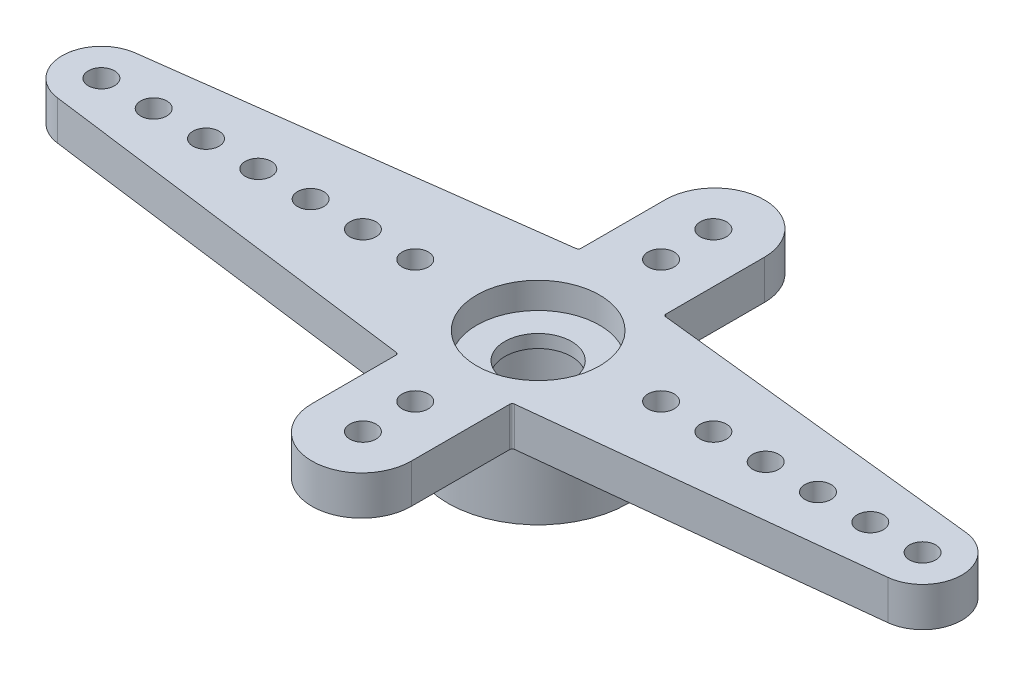
from build123d import *

# Parameters (mm, degrees)
IZIM1_R                     = 2.35
IZIM1_R_2                   = 0.5
Y_KSEKLIK_EKSTR_ZYON1_DEPTH = 1.5
IZIM1_3_R                   = 2.35
IZIM1_3_R_2                 = 1.275
Y_KSEKLIK_EKSTR_ZYON2_DEPTH = 0.5
IZIM2_R                     = 3.45
IZIM2_R_2                   = 2.3
Y_KSEKLIK_EKSTR_ZYON3_DEPTH = 2.5
RADYUS1_R                   = 0.1


with BuildPart() as part:
    # izim1 → Y_kseklik-Ekstr_zyon1 (new body)
    with BuildSketch(Plane(origin=(0, 0, 0), x_dir=(1, 0, 0), z_dir=(0, 1, 0))):
        with BuildLine():
            Line((1.9, 2.9), (1.9, 6.75))
            ThreePointArc((1.9, 6.75), (0, 8.65), (-1.9, 6.75))
            Line((-1.9, 6.75), (-1.9, 3.45))
            Line((-1.9, 3.45), (-16.894677741, 1.487313207))
            ThreePointArc((-16.894677741, 1.487313207), (-18.2, 0), (-16.894677741, -1.487313207))
            Line((-16.894677741, -1.487313207), (-1.9, -3.45))
            Line((-1.9, -3.45), (-1.9, -6.75))
            ThreePointArc((-1.9, -6.75), (0, -8.65), (1.9, -6.75))
            Line((1.9, -6.75), (1.9, -2.9))
            Line((1.9, -2.9), (14.862072923, -1.491218417))
            ThreePointArc((14.862072923, -1.491218417), (16.2, 0), (14.862072923, 1.491218417))
            Line((14.862072923, 1.491218417), (1.9, 2.9))
        make_face()
        Circle(IZIM1_R, mode=Mode.SUBTRACT)
        with Locations((-16.7, 0)):
            Circle(IZIM1_R_2, mode=Mode.SUBTRACT)
        with Locations((-14.7, 0)):
            Circle(IZIM1_R_2, mode=Mode.SUBTRACT)
        with Locations((-12.7, 0)):
            Circle(IZIM1_R_2, mode=Mode.SUBTRACT)
        with Locations((-10.7, 0)):
            Circle(IZIM1_R_2, mode=Mode.SUBTRACT)
        with Locations((-8.7, 0)):
            Circle(IZIM1_R_2, mode=Mode.SUBTRACT)
        with Locations((-6.7, 0)):
            Circle(IZIM1_R_2, mode=Mode.SUBTRACT)
        with Locations((-4.7, 0)):
            Circle(IZIM1_R_2, mode=Mode.SUBTRACT)
        with Locations((14.7, 0)):
            Circle(IZIM1_R_2, mode=Mode.SUBTRACT)
        with Locations((12.7, 0)):
            Circle(IZIM1_R_2, mode=Mode.SUBTRACT)
        with Locations((10.7, 0)):
            Circle(IZIM1_R_2, mode=Mode.SUBTRACT)
        with Locations((8.7, 0)):
            Circle(IZIM1_R_2, mode=Mode.SUBTRACT)
        with Locations((6.7, 0)):
            Circle(IZIM1_R_2, mode=Mode.SUBTRACT)
        with Locations((4.7, 0)):
            Circle(IZIM1_R_2, mode=Mode.SUBTRACT)
        with Locations((0, 6.7)):
            Circle(IZIM1_R_2, mode=Mode.SUBTRACT)
        with Locations((0, 4.7)):
            Circle(IZIM1_R_2, mode=Mode.SUBTRACT)
        with Locations((0, -6.7)):
            Circle(IZIM1_R_2, mode=Mode.SUBTRACT)
        with Locations((0, -4.7)):
            Circle(IZIM1_R_2, mode=Mode.SUBTRACT)
    extrude(amount=Y_KSEKLIK_EKSTR_ZYON1_DEPTH)

    # izim1_3 → Y_kseklik-Ekstr_zyon2 (add)
    with BuildSketch(Plane(origin=(0, 0, 0), x_dir=(1, 0, 0), z_dir=(0, 1, 0))):
        Circle(IZIM1_3_R)
        Circle(IZIM1_3_R_2, mode=Mode.SUBTRACT)
    extrude(amount=Y_KSEKLIK_EKSTR_ZYON2_DEPTH)

    # izim2 → Y_kseklik-Ekstr_zyon3 (add)
    with BuildSketch(Plane.XZ):
        Circle(IZIM2_R)
        Circle(IZIM2_R_2, mode=Mode.SUBTRACT)
    extrude(amount=Y_KSEKLIK_EKSTR_ZYON3_DEPTH)

    # Radyus1
    radyus1_edges = [part.edges().sort_by_distance(p)[0] for p in [
        (1.9, 0.75, -2.9),
        (1.9, 0.75, 2.9),
        (-1.9, 0.75, 3.45),
        (-1.9, 0.75, -3.45),
    ]]
    fillet(radyus1_edges, radius=RADYUS1_R)


solid = part.part
